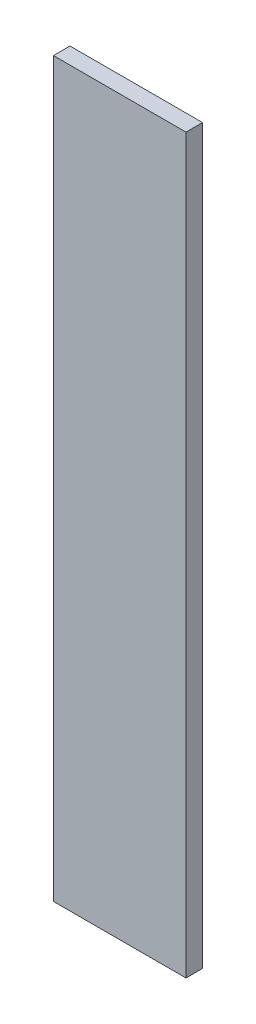
from build123d import *

# Parameters (mm, degrees)
SKETCH1_W           = 80
SKETCH1_H           = 442
BOSS_EXTRUDE1_DEPTH = 5


with BuildPart() as part:
    # Sketch1 → Boss-Extrude1 (new body, symmetric)
    with BuildSketch(Plane.XY):
        Rectangle(SKETCH1_W, SKETCH1_H)
    extrude(amount=BOSS_EXTRUDE1_DEPTH, both=True)


solid = part.part
